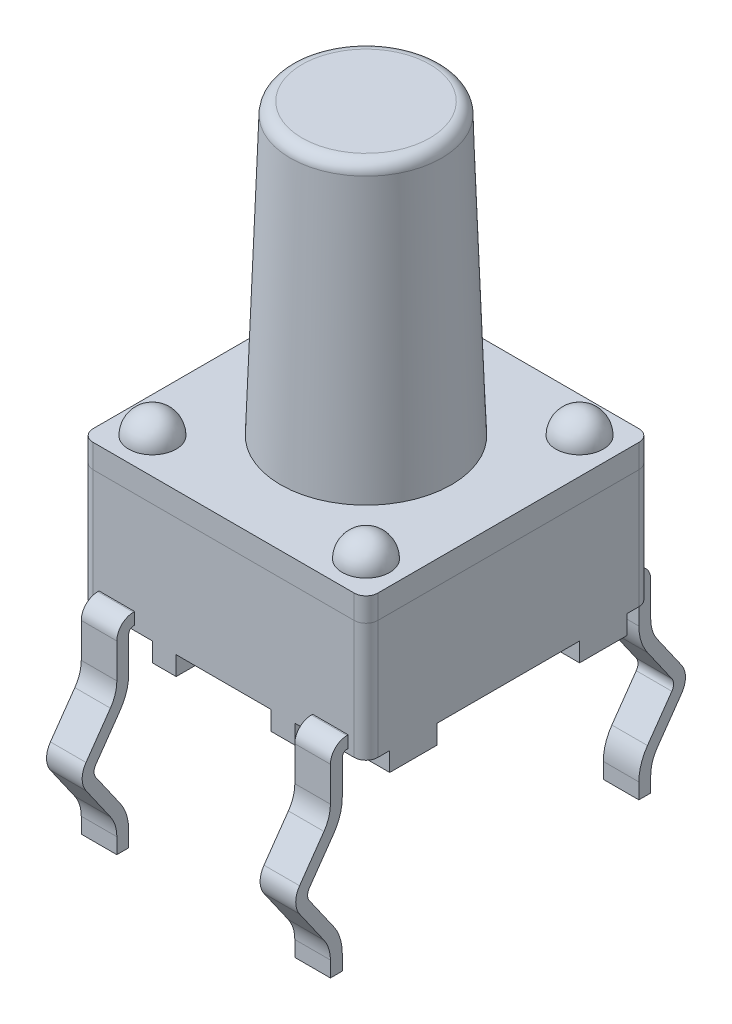
from build123d import *

# Parameters (mm, degrees)
SKETCH1_W            = 6
SKETCH1_H            = 6
EXTRUDE1_DEPTH       = 3.4
SKETCH2_W            = 1.5
SKETCH2_H            = 3
SKETCH2_H_2          = 0.5
SKETCH2_W_2          = 2
SKETCH2_H_3          = 6
SKETCH2_W_3          = 1
EXTRUDE2_DEPTH       = 0.4
REVOLVE1_ANGLE       = 180
LPATTERN1_COUNT      = 2
LPATTERN1_PITCH      = 4.5
LPATTERN1_COUNT_DIR2 = 2
LPATTERN1_PITCH_DIR2 = 4.5
SKETCH4_R            = 1.8
EXTRUDE3_DEPTH       = 6.1
EXTRUDE3_TAPER       = 2
EXTRUDE4_DEPTH       = 0.375
MIRROR2_COPY_1_DEPTH = 0.375
FILLET1_R            = 0.25


with BuildPart() as part:
    # Sketch1 → Extrude1 (new body)
    with BuildSketch(Plane(origin=(0, 0, 0), x_dir=(1, 0, 0), z_dir=(0, 1, 0))):
        Rectangle(SKETCH1_W, SKETCH1_H)
    extrude(amount=EXTRUDE1_DEPTH)

    # Sketch2 → Extrude2 (cut)
    with BuildSketch(Plane.XZ):
        with Locations((-2.25, 0)):
            Rectangle(SKETCH2_W, SKETCH2_H)
        with Locations((-2.25, -2.75)):
            Rectangle(SKETCH2_W, SKETCH2_H_2)
        with Locations((-2.25, 2.75)):
            Rectangle(SKETCH2_W, SKETCH2_H_2)
        Rectangle(SKETCH2_W_2, SKETCH2_H_3)
        with Locations((0, -2.25)):
            Rectangle(SKETCH2_W_3, SKETCH2_H_2, mode=Mode.SUBTRACT)
        with Locations((0, 2.25)):
            Rectangle(SKETCH2_W_3, SKETCH2_H_2, mode=Mode.SUBTRACT)
        Rectangle(SKETCH2_W_3, SKETCH2_H_2, mode=Mode.SUBTRACT)
        with Locations((2.25, 2.75)):
            Rectangle(SKETCH2_W, SKETCH2_H_2)
        with Locations((2.25, -2.75)):
            Rectangle(SKETCH2_W, SKETCH2_H_2)
        with Locations((2.25, 0)):
            Rectangle(SKETCH2_W, SKETCH2_H)
    extrude(amount=-EXTRUDE2_DEPTH, mode=Mode.SUBTRACT)

    # Sketch3 → Revolve1 (revolve)
    with BuildSketch(Plane(origin=(0, 3.4, 0), x_dir=(1, 0, 0), z_dir=(0, 1, 0))):
        with BuildLine():
            Line((-2.25, 1.75), (-2.25, 2.75))
            ThreePointArc((-2.25, 2.75), (-2.75, 2.25), (-2.25, 1.75))
        make_face()
    revolve1 = revolve(axis=Axis((-2.25, 3.4, -1.75), (0, 0, -1)), revolution_arc=REVOLVE1_ANGLE)

    # LPattern1: Revolve1 2 × 2
    with Locations(*[(i * LPATTERN1_PITCH, 0, j * LPATTERN1_PITCH_DIR2) for i in range(LPATTERN1_COUNT) for j in range(LPATTERN1_COUNT_DIR2) if (i, j) != (0, 0)]):
        add(revolve1)

    # Sketch4 → Extrude3 (add)
    with BuildSketch(Plane(origin=(0, 3.4, 0), x_dir=(1, 0, 0), z_dir=(0, 1, 0))):
        Circle(SKETCH4_R)
    extrude(amount=EXTRUDE3_DEPTH, taper=EXTRUDE3_TAPER)

    # Sketch5 → Extrude4 (add, symmetric)
    with BuildSketch(Plane(origin=(2.25, 0, 0), x_dir=(0, 0, -1), z_dir=(1, 0, 0))):
        with BuildLine():
            Line((3.125, -3.5), (3.125, -3.172113494))
            ThreePointArc((3.125, -3.172113494), (3.171283049, -2.871407695), (3.305847956, -2.598537058))
            Line((3.305847956, -2.598537058), (3.819675491, -1.864715287))
            ThreePointArc((3.819675491, -1.864715287), (3.855845082, -1.75), (3.819675491, -1.635284713))
            Line((3.819675491, -1.635284713), (3.305847956, -0.901462942))
            ThreePointArc((3.305847956, -0.901462942), (3.171283049, -0.628592305), (3.125, -0.327886506))
            Line((3.125, -0.327886506), (3.125, 0.4))
            ThreePointArc((3.125, 0.4), (3.095710678, 0.470710678), (3.025, 0.5))
            Line((3.025, 0.5), (3, 0.5))
            Line((3, 0.5), (3, 0.75))
            Line((3, 0.75), (3.025, 0.75))
            ThreePointArc((3.025, 0.75), (3.272487373, 0.647487373), (3.375, 0.4))
            Line((3.375, 0.4), (3.375, -0.327886506))
            ThreePointArc((3.375, -0.327886506), (3.409712287, -0.553415856), (3.510635967, -0.758068833))
            Line((3.510635967, -0.758068833), (4.024463502, -1.491890604))
            ThreePointArc((4.024463502, -1.491890604), (4.105845082, -1.75), (4.024463502, -2.008109396))
            Line((4.024463502, -2.008109396), (3.510635967, -2.741931167))
            ThreePointArc((3.510635967, -2.741931167), (3.409712287, -2.946584144), (3.375, -3.172113494))
            Line((3.375, -3.172113494), (3.375, -3.5))
            Line((3.375, -3.5), (3.125, -3.5))
        make_face()
    extrude4 = extrude(amount=EXTRUDE4_DEPTH, both=True)

    # Mirror1: Extrude4 across plane
    add(extrude4.mirror(Plane.XY))

    # Mirror2: Extrude4 across plane
    add(extrude4.mirror(Plane(origin=(0, 0, 0), x_dir=(0, 0, 1), z_dir=(1, 0, 0))))

    # Mirror2 copy 1 sketch → Mirror2 copy 1 (add, symmetric)
    with BuildSketch(Plane.ZY.offset(2.25)):
        with BuildLine():
            Line((3.125, -3.5), (3.125, -3.172113494))
            ThreePointArc((3.125, -3.172113494), (3.171283049, -2.871407695), (3.305847956, -2.598537058))
            Line((3.305847956, -2.598537058), (3.819675491, -1.864715287))
            ThreePointArc((3.819675491, -1.864715287), (3.855845082, -1.75), (3.819675491, -1.635284713))
            Line((3.819675491, -1.635284713), (3.305847956, -0.901462942))
            ThreePointArc((3.305847956, -0.901462942), (3.171283049, -0.628592305), (3.125, -0.327886506))
            Line((3.125, -0.327886506), (3.125, 0.4))
            ThreePointArc((3.125, 0.4), (3.095710678, 0.470710678), (3.025, 0.5))
            Line((3.025, 0.5), (3, 0.5))
            Line((3, 0.5), (3, 0.75))
            Line((3, 0.75), (3.025, 0.75))
            ThreePointArc((3.025, 0.75), (3.272487373, 0.647487373), (3.375, 0.4))
            Line((3.375, 0.4), (3.375, -0.327886506))
            ThreePointArc((3.375, -0.327886506), (3.409712287, -0.553415856), (3.510635967, -0.758068833))
            Line((3.510635967, -0.758068833), (4.024463502, -1.491890604))
            ThreePointArc((4.024463502, -1.491890604), (4.105845082, -1.75), (4.024463502, -2.008109396))
            Line((4.024463502, -2.008109396), (3.510635967, -2.741931167))
            ThreePointArc((3.510635967, -2.741931167), (3.409712287, -2.946584144), (3.375, -3.172113494))
            Line((3.375, -3.172113494), (3.375, -3.5))
            Line((3.375, -3.5), (3.125, -3.5))
        make_face()
    extrude(amount=MIRROR2_COPY_1_DEPTH, both=True)

    # Fillet1
    fillet1_edges = [part.edges().sort_by_distance(p)[0] for p in [
        (-1.586983306, 9.5, 0),
        (3, 1.9, 3),
        (-3, 1.9, 3),
        (-3, 1.9, -3),
        (3, 1.9, -3),
        (3, 1.9, 3),
        (-3, 1.9, 3),
        (-3, 1.9, -3),
        (3, 1.9, -3),
    ]]
    fillet(fillet1_edges, radius=FILLET1_R)


solid = part.part
